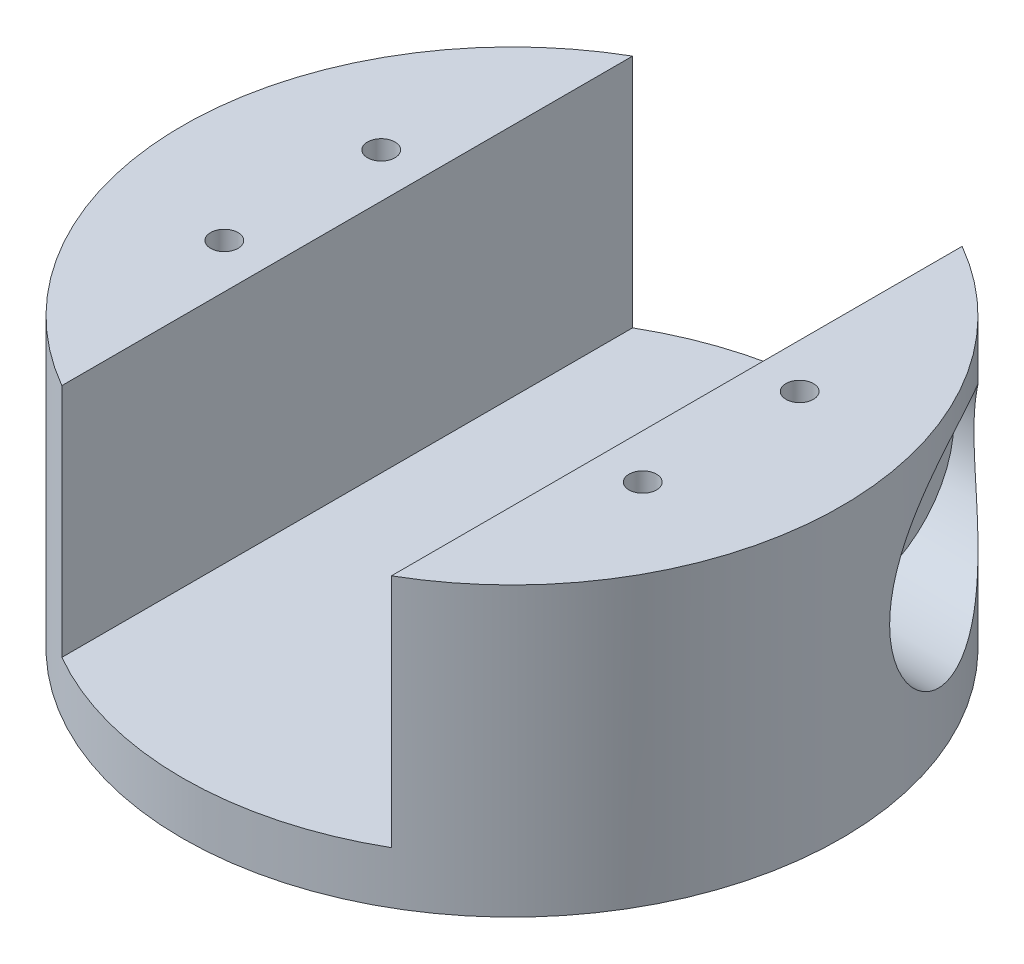
from build123d import *

# Parameters (mm, degrees)
SKETCH1_R           = 17.5
BOSS_EXTRUDE1_DEPTH = 15
SKETCH2_R           = 63
BOSS_EXTRUDE2_DEPTH = 10
BOSS_EXTRUDE3_DEPTH = 45
SKETCH5_R           = 2.625
CUT_EXTRUDE1_DEPTH  = 6
SKETCH7_R           = 20
CUT_EXTRUDE2_DEPTH  = 28.5
SKETCH9_R           = 2
SKETCH9_R_2         = 6.5
CUT_EXTRUDE3_DEPTH  = 31.5


with BuildPart() as part:
    # Sketch1 → Boss-Extrude1 (new body)
    with BuildSketch(Plane(origin=(0, 0, 0), x_dir=(1, 0, 0), z_dir=(0, 1, 0))):
        with Locations(Location((0, 0, 0), (0, 0, 270))):
            Circle(SKETCH1_R)
    extrude(amount=BOSS_EXTRUDE1_DEPTH)

    # Sketch2 → Boss-Extrude2 (add)
    with BuildSketch(Plane(origin=(0, 15, 0), x_dir=(1, 0, 0), z_dir=(0, 1, 0))):
        with Locations(Location((0, 0, 0), (0, 0, 270))):
            Circle(SKETCH2_R)
    extrude(amount=BOSS_EXTRUDE2_DEPTH)

    # Sketch4 → Boss-Extrude3 (add)
    with BuildSketch(Plane(origin=(0, 25, 0), x_dir=(1, 0, 0), z_dir=(0, 1, 0))):
        with BuildLine():
            Line((-31.5, 44), (-31.5, 54.559600438))
            ThreePointArc((-31.5, 54.559600438), (-63, 0), (-31.5, -54.559600438))
            Line((-31.5, -54.559600438), (-31.5, -44))
            Line((-31.5, -44), (-31.5, 44))
        make_face()
        with BuildLine():
            Line((31.5, -44), (31.5, 44))
            Line((31.5, 44), (31.5, 54.559600438))
            ThreePointArc((31.5, 54.559600438), (63, 0), (31.5, -54.559600438))
            Line((31.5, -54.559600438), (31.5, -44))
        make_face()
    extrude(amount=BOSS_EXTRUDE3_DEPTH)

    # Sketch5 → Cut-Extrude1 (cut)
    with BuildSketch(Plane(origin=(0, 70, 0), x_dir=(1, 0, 0), z_dir=(0, 1, 0))):
        with Locations(Location((-40, 15, 0), (0, 0, 270))):
            Circle(SKETCH5_R)
        with Locations(Location((-40, -15, 0), (0, 0, 270))):
            Circle(SKETCH5_R)
        with Locations(Location((40, -15, 0), (0, 0, 90))):
            Circle(SKETCH5_R)
        with Locations(Location((40, 15, 0), (0, 0, 90))):
            Circle(SKETCH5_R)
    extrude(amount=-CUT_EXTRUDE1_DEPTH, mode=Mode.SUBTRACT)

    # Sketch7 → Cut-Extrude2 (cut)
    with BuildSketch(Plane(origin=(63, 0, 0), x_dir=(0, 0, -1), z_dir=(1, 0, 0))):
        with Locations((30, 45)):
            Circle(SKETCH7_R)
    extrude(amount=-CUT_EXTRUDE2_DEPTH, mode=Mode.SUBTRACT)

    # Sketch9 → Cut-Extrude3 (cut)
    with BuildSketch(Plane(origin=(63, 0, 0), x_dir=(0, 0, -1), z_dir=(1, 0, 0))):
        with Locations((21.019743879, 36.019743879)):
            Circle(SKETCH9_R)
        with Locations((21.019743879, 53.980256121)):
            Circle(SKETCH9_R)
        with Locations((38.980256121, 53.980256121)):
            Circle(SKETCH9_R)
        with Locations((38.980256121, 36.019743879)):
            Circle(SKETCH9_R)
        with Locations((30, 45)):
            Circle(SKETCH9_R_2)
    extrude(amount=-CUT_EXTRUDE3_DEPTH, mode=Mode.SUBTRACT)


solid = part.part
